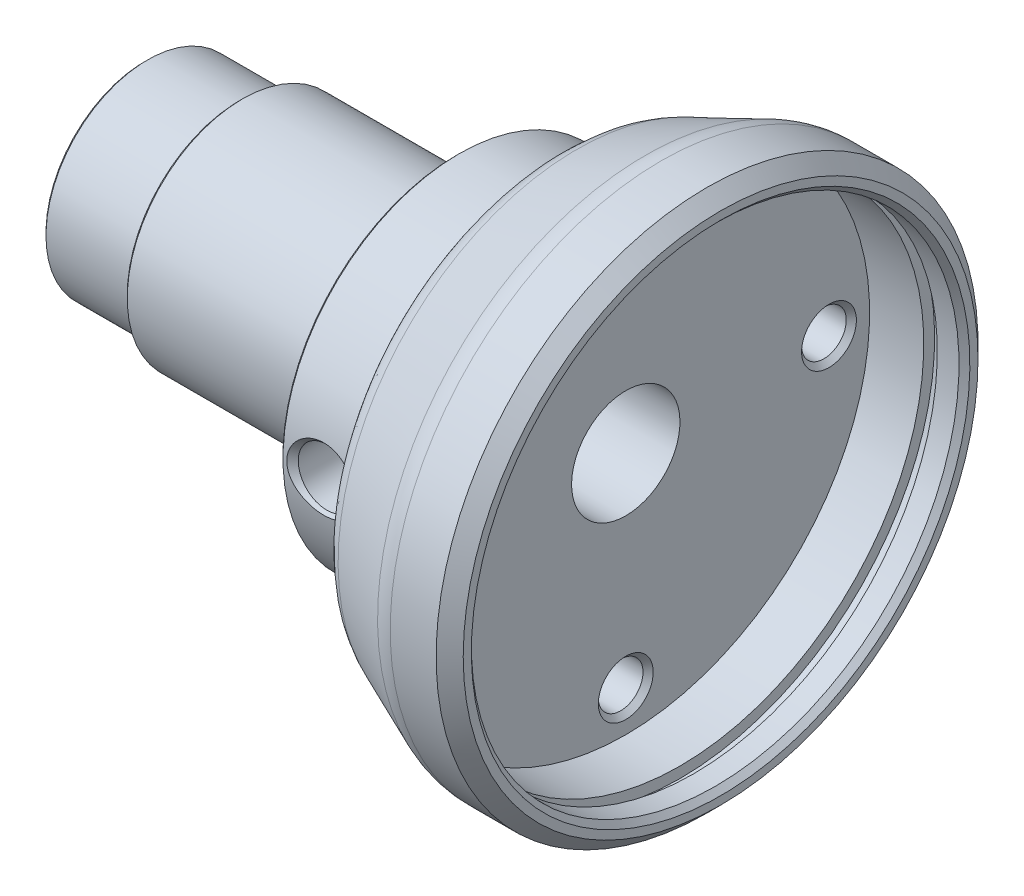
from build123d import *

# Parameters (mm, degrees)
FASE6_SIZE                     = 1
FASE7_SIZE                     = 0.4
VERRUNDUNG1_R                  = 3
VERRUNDUNG2_R                  = 1
M4_GEWINDEBOHRUNG1_D           = 3.3
M4_GEWINDEBOHRUNG1_DEPTH       = 11.5
M4_GEWINDEBOHRUNG1_CSINK_D     = 4.05
M4_GEWINDEBOHRUNG1_CSINK_ANGLE = 90
M4_GEWINDEBOHRUNG1_TIP         = 0.991420021
M5_GEWINDEBOHRUNG2_D           = 4.2
M5_GEWINDEBOHRUNG2_DEPTH       = 14
M5_GEWINDEBOHRUNG2_CSINK_D     = 5.05
M5_GEWINDEBOHRUNG2_CSINK_ANGLE = 90
M5_GEWINDEBOHRUNG2_TIP         = 1.2618073


with BuildPart() as part:
    # Skizze1 → Rotation1 (revolve)
    with BuildSketch(Plane.XY):
        with BuildLine():
            Line((7.2, -8.5), (22, -8.5))
            ThreePointArc((22, -8.5), (22.707106781, -8.792893219), (23, -9.5))
            Line((23, -9.5), (23, -12.8))
            Line((23, -12.8), (23.2, -13))
            Line((23.2, -13), (29.5, -13))
            Line((29.5, -13), (30.5, -17.028676287))
            Line((30.5, -17.028676287), (36.938163513, -19.76151456))
            ThreePointArc((36.938163513, -19.76151456), (37.512253095, -19.939774114), (38.110356898, -20))
            Line((38.110356898, -20), (42.5, -20))
            Line((42.5, -20), (42.5, -18))
            Line((42.5, -18), (40.5, -18))
            Line((40.5, -18), (40.5, -18.8))
            Line((40.5, -18.8), (39.5, -18.8))
            Line((39.5, -18.8), (39.5, -18))
            Line((39.5, -18), (35.5, -18))
            Line((35.5, -18), (35.5, -4))
            Line((35.5, -4), (0.2, -4))
            Line((0.2, -4), (0, -4.2))
            Line((0, -4.2), (0, -7.3))
            Line((0, -7.3), (0.2, -7.5))
            Line((0.2, -7.5), (7, -7.5))
            Line((7, -7.5), (7, -8.3))
            Line((7, -8.3), (7.2, -8.5))
        make_face()
    revolve(axis=Axis((-24.34679744, 0, 0), (1, 0, 0)))

    # Fase6
    fase6_edges = [part.edges().sort_by_distance(p)[0] for p in [
        (42.5, 20, 0),
    ]]
    chamfer(fase6_edges, length=FASE6_SIZE)

    # Fase7
    fase7_edges = [part.edges().sort_by_distance(p)[0] for p in [
        (42.5, 18, 0),
    ]]
    chamfer(fase7_edges, length=FASE7_SIZE)

    # Verrundung1
    verrundung1_edges = [part.edges().sort_by_distance(p)[0] for p in [
        (30.5, 17.028676287, 0),
    ]]
    fillet(verrundung1_edges, radius=VERRUNDUNG1_R)

    # Verrundung2
    verrundung2_edges = [part.edges().sort_by_distance(p)[0] for p in [
        (29.5, 13, 0),
    ]]
    fillet(verrundung2_edges, radius=VERRUNDUNG2_R)

    # M4 Gewindebohrung1
    with Locations(Plane(origin=(35.5, 15, 0), x_dir=(0, 1, 0), z_dir=(1, 0, 0))):
        with Locations((0, 0), (-15, 15), (-30, 0), (-15, -15)):
            CounterSinkHole(M4_GEWINDEBOHRUNG1_D / 2, M4_GEWINDEBOHRUNG1_CSINK_D / 2, depth=M4_GEWINDEBOHRUNG1_DEPTH, counter_sink_angle=M4_GEWINDEBOHRUNG1_CSINK_ANGLE)
            with Locations((0, 0, -(M4_GEWINDEBOHRUNG1_DEPTH + M4_GEWINDEBOHRUNG1_TIP / 2))):  # 118° drill point
                Cone(0, M4_GEWINDEBOHRUNG1_D / 2, M4_GEWINDEBOHRUNG1_TIP, mode=Mode.SUBTRACT)

    # M5 Gewindebohrung2
    with Locations(Plane.XY.offset(13)):
        with Locations((26, 0)):
            CounterSinkHole(M5_GEWINDEBOHRUNG2_D / 2, M5_GEWINDEBOHRUNG2_CSINK_D / 2, depth=M5_GEWINDEBOHRUNG2_DEPTH, counter_sink_angle=M5_GEWINDEBOHRUNG2_CSINK_ANGLE)
            with Locations((0, 0, -(M5_GEWINDEBOHRUNG2_DEPTH + M5_GEWINDEBOHRUNG2_TIP / 2))):  # 118° drill point
                Cone(0, M5_GEWINDEBOHRUNG2_D / 2, M5_GEWINDEBOHRUNG2_TIP, mode=Mode.SUBTRACT)


solid = part.part
